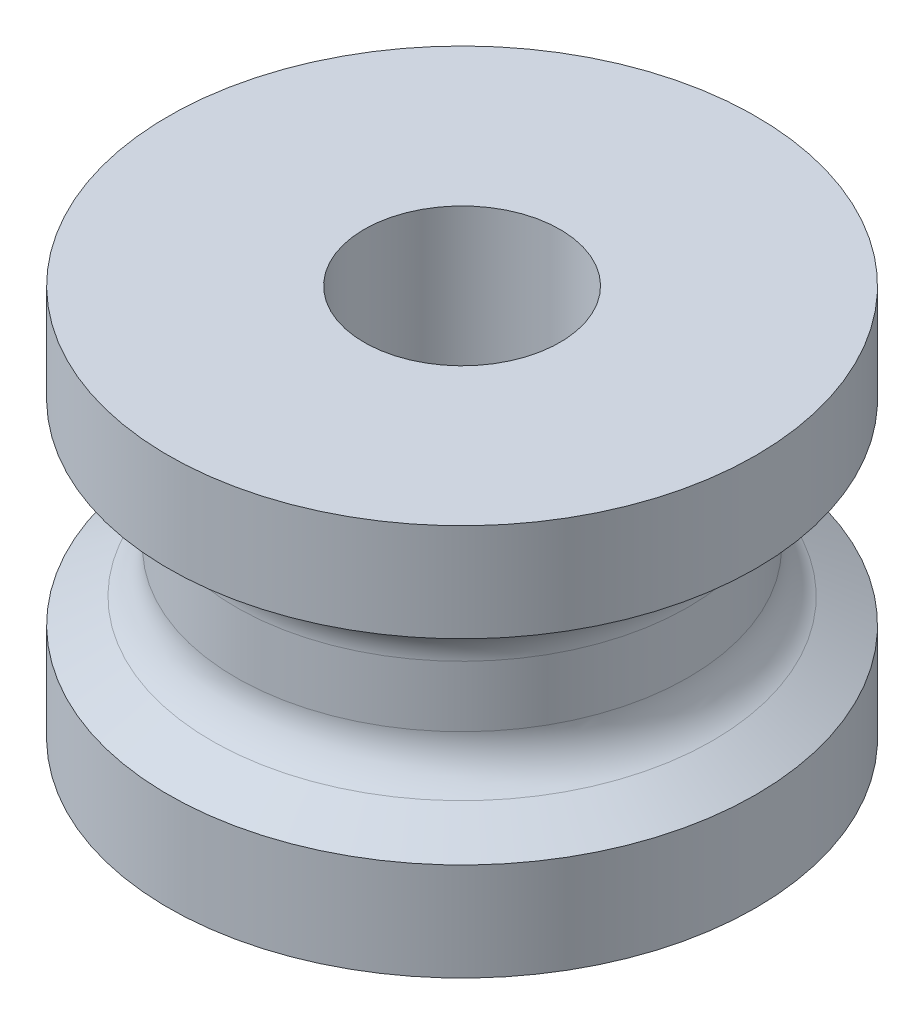
from build123d import *

# Parameters (mm, degrees)
SKETCH2_R          = 1
CUT_EXTRUDE1_DEPTH = 5


with BuildPart() as part:
    # Sketch1 → Revolve2 (revolve)
    with BuildSketch(Plane.XY):
        with BuildLine():
            Line((0, 2), (3, 2))
            Line((3, 2), (3, 1))
            Line((3, 1), (2.557179677, 0.744337567))
            ThreePointArc((2.557179677, 0.744337567), (2.374166975, 0.561324865), (2.307179677, 0.311324865))
            Line((2.307179677, 0.311324865), (2.307179677, -0.311324865))
            ThreePointArc((2.307179677, -0.311324865), (2.374166975, -0.561324865), (2.557179677, -0.744337567))
            Line((2.557179677, -0.744337567), (3, -1))
            Line((3, -1), (3, -2))
            Line((3, -2), (0, -2))
            Line((0, -2), (0, 2))
        make_face()
    revolve(axis=Axis((0, -2, 0), (0, 1, 0)))

    # Sketch2 → Cut-Extrude1 (cut, through all)
    with BuildSketch(Plane(origin=(0, 2, 0), x_dir=(1, 0, 0), z_dir=(0, 1, 0))):
        Circle(SKETCH2_R)
    extrude(amount=-CUT_EXTRUDE1_DEPTH, mode=Mode.SUBTRACT)


solid = part.part
